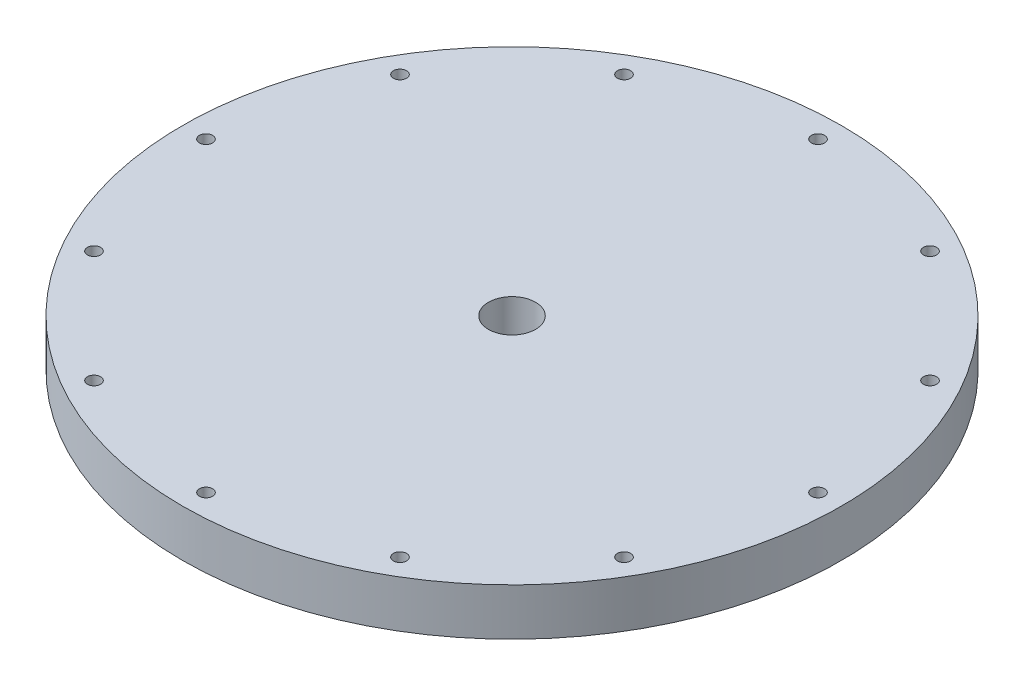
from build123d import *

# Parameters (mm, degrees)
SKETCH5_R          = 0.889
CUT_EXTRUDE1_DEPTH = 12.7


with BuildPart() as part:
    # Sketch2 → Revolve1 (revolve)
    with BuildSketch(Plane.XY):
        Polygon((-38.1, -5.147815534), (-44.45, -5.147815534), (-44.45, 1.202184466), (-3.175, 1.202184466), (-3.175, -5.147815534), (-34.925, -5.147815534), align=None)
    revolve(axis=Axis((0, 49.967071373, 0), (0, -1, 0)))

    # Sketch5 → Cut-Extrude1 (cut)
    with BuildSketch(Plane(origin=(0, 1.202184466, 0), x_dir=(1, 0, 0), z_dir=(0, 1, 0))):
        with Locations((-41.275, 0)):
            Circle(SKETCH5_R)
        with Locations((-35.745198541, 20.6375)):
            Circle(SKETCH5_R)
        with Locations((-20.6375, 35.745198541)):
            Circle(SKETCH5_R)
        with Locations((0, 41.275)):
            Circle(SKETCH5_R)
        with Locations((20.6375, 35.745198541)):
            Circle(SKETCH5_R)
        with Locations((35.745198541, 20.6375)):
            Circle(SKETCH5_R)
        with Locations((41.275, 0)):
            Circle(SKETCH5_R)
        with Locations((35.745198541, -20.6375)):
            Circle(SKETCH5_R)
        with Locations((20.6375, -35.745198541)):
            Circle(SKETCH5_R)
        with Locations((0, -41.275)):
            Circle(SKETCH5_R)
        with Locations((-20.6375, -35.745198541)):
            Circle(SKETCH5_R)
        with Locations((-35.745198541, -20.6375)):
            Circle(SKETCH5_R)
    extrude(amount=-CUT_EXTRUDE1_DEPTH, mode=Mode.SUBTRACT)


solid = part.part
